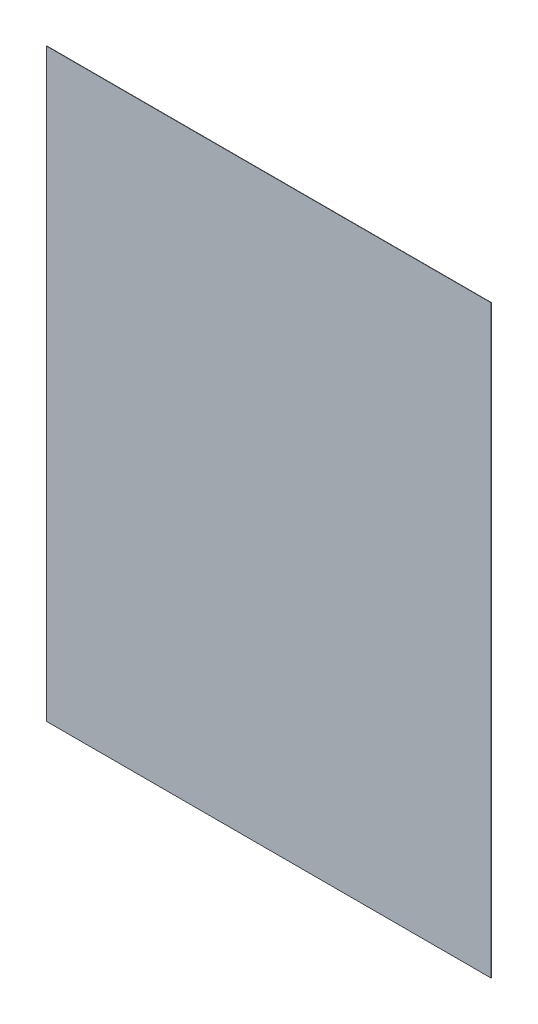
from build123d import *

# Parameters (mm, degrees)
SKETCH1_W   = 156.1
SKETCH1_H   = 205.5
POUCH_DEPTH = 0.112


with BuildPart() as part:
    # Sketch1 → Pouch (new body)
    with BuildSketch(Plane.XY):
        Rectangle(SKETCH1_W, SKETCH1_H)
    extrude(amount=POUCH_DEPTH)


solid = part.part
